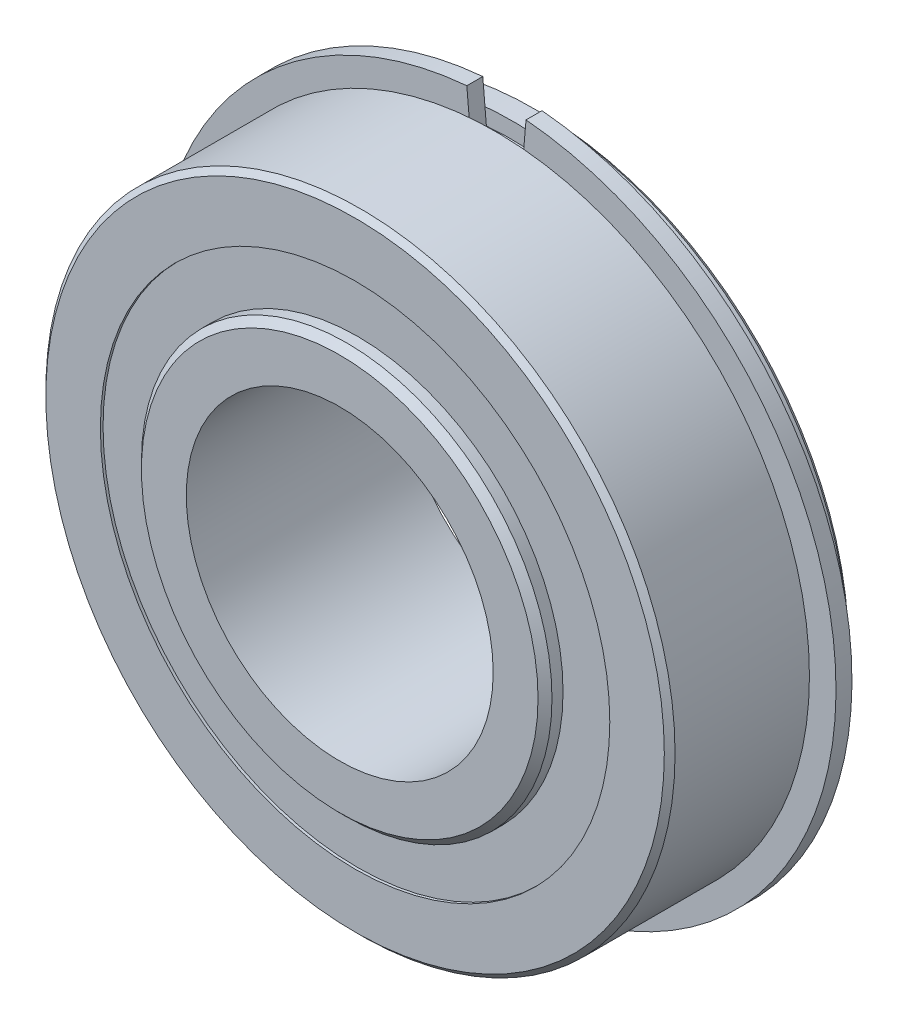
from build123d import *

# Parameters (mm, degrees)
CIRPATTERN1_COUNT = 8
SKETCH5_W         = 4.969984256
SKETCH5_H         = 5.113576622
SKETCH6_W         = 1.8161
SKETCH6_H         = 1.681320253
EXTRUDE1_DEPTH    = 1.651


with BuildPart() as part:
    # Sketch1 → Revolve1 (revolve)
    with BuildSketch(Plane(origin=(0, 0, 0), x_dir=(0, 0, -1), z_dir=(1, 0, 0))):
        with BuildLine():
            Line((8.969375, 32.54375), (-8.969375, 32.54375))
            Line((-8.969375, 32.54375), (-9.525, 31.988125))
            Line((-9.525, 31.988125), (-9.525, 26.347976622))
            Line((-9.525, 26.347976622), (-3.704166667, 26.347976622))
            ThreePointArc((-3.704166667, 26.347976622), (0, 28.486578244), (3.704166667, 26.347976622))
            Line((3.704166667, 26.347976622), (9.525, 26.347976622))
            Line((9.525, 26.347976622), (9.525, 31.988125))
            Line((9.525, 31.988125), (8.969375, 32.54375))
        make_face()
    revolve(axis=Axis((0, 0, 11.1125), (0, 0, -1)))

    # Sketch6 → Cut-Revolve1 (revolve, cut)
    with BuildSketch(Plane(origin=(0, 0, 0), x_dir=(0, 0, -1), z_dir=(1, 0, 0))):
        with Locations((5.838825, 31.703089874)):
            Rectangle(SKETCH6_W, SKETCH6_H)
    revolve(axis=Axis((0, 0, 11.1125), (0, 0, -1)), mode=Mode.SUBTRACT)


with BuildPart() as body_2:
    # Sketch3 → Revolve3 (revolve)
    with BuildSketch(Plane(origin=(0, 0, 0), x_dir=(0, 0, -1), z_dir=(1, 0, 0))):
        with BuildLine():
            Line((-10.390662895, 21.2344), (-3.073107766, 21.2344))
            ThreePointArc((-3.073107766, 21.2344), (0, 19.932171756), (3.073107766, 21.2344))
            Line((3.073107766, 21.2344), (10.390662895, 21.2344))
            Line((10.390662895, 21.2344), (11.1125, 20.512562895))
            Line((11.1125, 20.512562895), (11.1125, 15.875))
            Line((11.1125, 15.875), (-11.1125, 15.875))
            Line((-11.1125, 15.875), (-11.1125, 20.512562895))
            Line((-11.1125, 20.512562895), (-10.390662895, 21.2344))
        make_face()
    revolve(axis=Axis((0, 0, 11.1125), (0, 0, -1)))


with BuildPart() as body_3:
    # Sketch4 → Revolve4 (revolve)
    with BuildSketch(Plane(origin=(0, 0, 0), x_dir=(0, 0, -1), z_dir=(1, 0, 0))):
        with BuildLine():
            Line((-4.277203244, 24.209375), (4.277203244, 24.209375))
            ThreePointArc((4.277203244, 24.209375), (0, 28.486578244), (-4.277203244, 24.209375))
        make_face()
    revolve(axis=Axis((0, 24.209375, 4.277203244), (0, 0, -1)))


with BuildPart() as cirpattern1_1:
    # CirPattern1: pattern copy
    add(body_3.part.rotate(Axis((0, 0, -11.1125), (0, 0, 1)), 1 * 360 / CIRPATTERN1_COUNT))


with BuildPart() as cirpattern1_2:
    # CirPattern1: pattern copy
    add(body_3.part.rotate(Axis((0, 0, -11.1125), (0, 0, 1)), 2 * 360 / CIRPATTERN1_COUNT))


with BuildPart() as cirpattern1_3:
    # CirPattern1: pattern copy
    add(body_3.part.rotate(Axis((0, 0, -11.1125), (0, 0, 1)), 3 * 360 / CIRPATTERN1_COUNT))


with BuildPart() as cirpattern1_4:
    # CirPattern1: pattern copy
    add(body_3.part.rotate(Axis((0, 0, -11.1125), (0, 0, 1)), 4 * 360 / CIRPATTERN1_COUNT))


with BuildPart() as cirpattern1_5:
    # CirPattern1: pattern copy
    add(body_3.part.rotate(Axis((0, 0, -11.1125), (0, 0, 1)), 5 * 360 / CIRPATTERN1_COUNT))


with BuildPart() as cirpattern1_6:
    # CirPattern1: pattern copy
    add(body_3.part.rotate(Axis((0, 0, -11.1125), (0, 0, 1)), 6 * 360 / CIRPATTERN1_COUNT))


with BuildPart() as cirpattern1_7:
    # CirPattern1: pattern copy
    add(body_3.part.rotate(Axis((0, 0, -11.1125), (0, 0, 1)), 7 * 360 / CIRPATTERN1_COUNT))


with BuildPart() as body_11:
    # Sketch5 → Revolve5 (revolve)
    with BuildSketch(Plane(origin=(0, 0, 0), x_dir=(0, 0, -1), z_dir=(1, 0, 0))):
        with Locations((-6.762195372, 23.791188311)):
            Rectangle(SKETCH5_W, SKETCH5_H)
        with Locations((6.762195372, 23.791188311)):
            Rectangle(SKETCH5_W, SKETCH5_H)
    revolve(axis=Axis((0, 0, 11.1125), (0, 0, -1)))


with BuildPart() as body_12:
    # Sketch7 → Extrude1 (new body)
    with BuildSketch(Plane.XY.offset(-6.746875)):
        with BuildLine():
            Line((2.689837988, 30.744988884), (3.061624362, 34.994526594))
            ThreePointArc((3.061624362, 34.994526594), (0, -35.1282), (-3.061624362, 34.994526594))
            Line((-3.061624362, 34.994526594), (-2.689837988, 30.744988884))
            ThreePointArc((-2.689837988, 30.744988884), (0, -30.862429747), (2.689837988, 30.744988884))
        make_face()
    extrude(amount=EXTRUDE1_DEPTH)


solid = Compound([part.part, body_2.part, body_3.part, cirpattern1_1.part, cirpattern1_2.part, cirpattern1_3.part, cirpattern1_4.part, cirpattern1_5.part, cirpattern1_6.part, cirpattern1_7.part, body_11.part, body_12.part])
